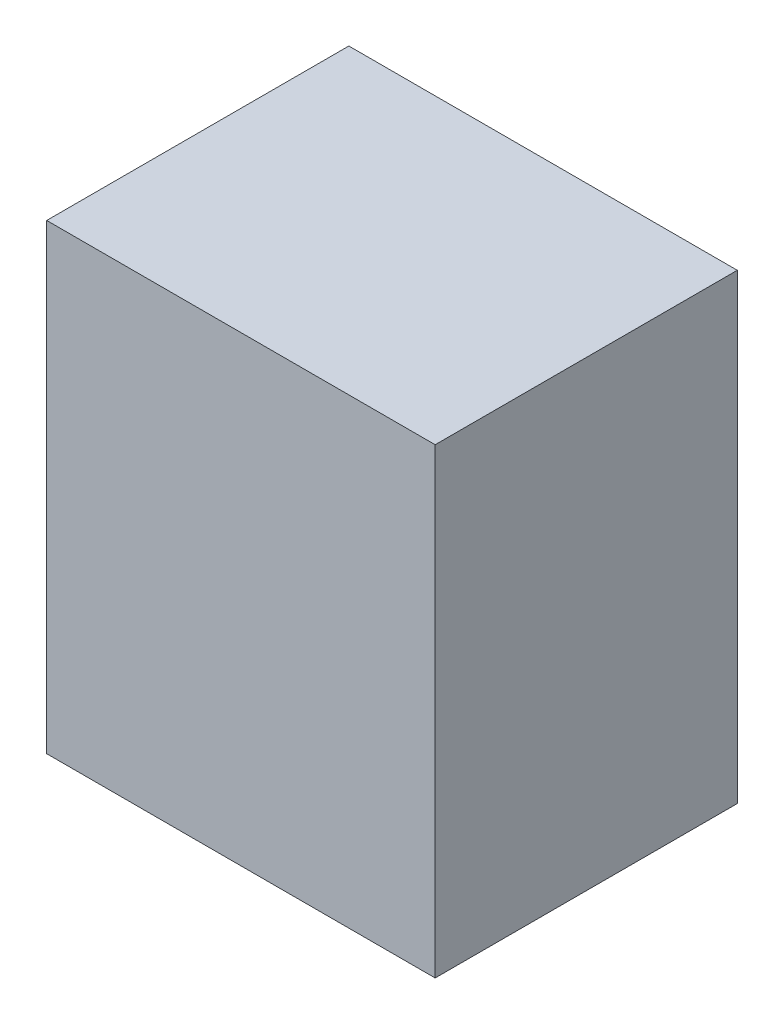
from build123d import *

# Parameters (mm, degrees)
SKETCH1_W           = 90
SKETCH1_H           = 70
BOSS_EXTRUDE1_DEPTH = 107


with BuildPart() as part:
    # Sketch1 → Boss-Extrude1 (new body)
    with BuildSketch(Plane(origin=(0, 0, 0), x_dir=(1, 0, 0), z_dir=(0, 1, 0))):
        with Locations((45, 35)):
            Rectangle(SKETCH1_W, SKETCH1_H)
    extrude(amount=BOSS_EXTRUDE1_DEPTH)


solid = part.part
